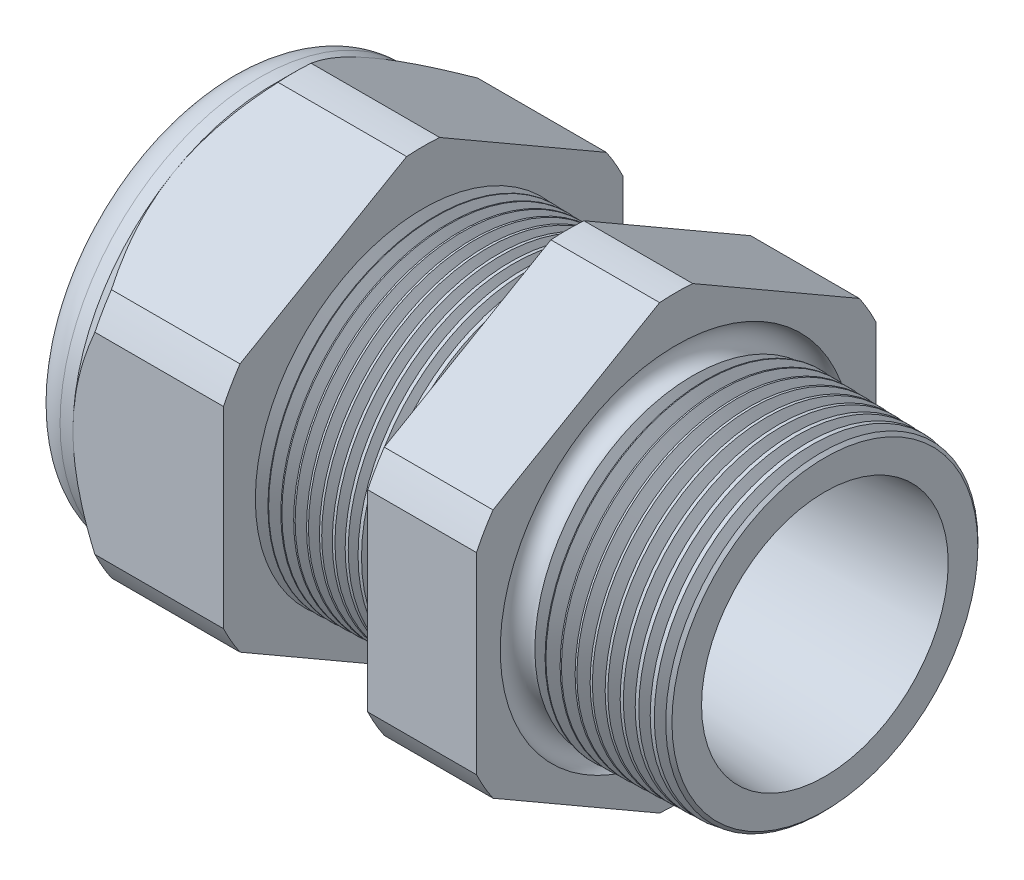
from build123d import *

# Parameters (mm, degrees)
SKETCH12_OUTSIDE_W = 65.04
SKETCH12_OUTSIDE_H = 65.04
CUT_EXTRUDE2_DEPTH = 34.014
FILLET4_R          = 2.032
SKETCH19_OUTSIDE_W = 39.986
SKETCH19_OUTSIDE_H = 42.612
SKETCH19_OUTSIDE_R = 11.938
CUT_EXTRUDE3_DEPTH = 1.999996
CUT_EXTRUDE3_DRAFT = -45
CHAMFER1_SIZE      = 0.260919487
CHAMFER1_SIZE2     = 0.254
SKETCH21_R         = 5.969
PLUG_DEPTH         = 6.35
SKETCH22_R         = 5.715
CUT_EXTRUDE4_DEPTH = 0.508
SKETCH27_R         = 1.524
PLUGHOLES_DEPTH    = 36.306
CIRPATTERN1_COUNT  = 3
LPATTERN1_COUNT    = 11
LPATTERN1_PITCH    = 0.762
LPATTERN2_COUNT    = 10
LPATTERN2_PITCH    = 0.889
SKETCH32_R         = 0.889


with BuildPart() as part:
    # Sketch10 → Revolve2 (revolve)
    with BuildSketch(Plane.XY, mode=Mode.PRIVATE) as revolve2_sk:
        Polygon((-34.798, 5.969), (-22.998, 5.969), (1.016, 7.372171279), (1.016, 9.404171279), (-7.874, 9.636964122), (-7.874, 23.876), (-14.374, 23.876), (-14.374, 9.807172612), (-22.998, 10.033), (-22.998, 23.876), (-31.998, 23.876), (-31.998, 11.938), (-34.798, 11.938), align=None)
    revolve(revolve2_sk.sketch.rotate(Axis((0, 0, 0), (-1, 0, 0)), 90), axis=Axis((0, 0, 0), (-1, 0, 0)))  # turned: the seam where the file's is

    # Sketch12 outside → Cut-Extrude2 (cut, through all)
    with BuildSketch(Plane.ZY.offset(31.998)):
        Rectangle(SKETCH12_OUTSIDE_W, SKETCH12_OUTSIDE_H)
        with BuildLine():
            Line((-0.98819228, 13.214281948), (-10.94980772, 7.462940592))
            ThreePointArc((-10.94980772, 7.462940592), (-11.47585851, 6.62559), (-11.938, 5.751341356))
            Line((-11.938, 5.751341356), (-11.938, -5.751341356))
            ThreePointArc((-11.938, -5.751341356), (-11.47585851, -6.62559), (-10.94980772, -7.462940592))
            Line((-10.94980772, -7.462940592), (-0.98819228, -13.214281948))
            ThreePointArc((-0.98819228, -13.214281948), (0, -13.25118), (0.98819228, -13.214281948))
            Line((0.98819228, -13.214281948), (10.94980772, -7.462940592))
            ThreePointArc((10.94980772, -7.462940592), (11.47585851, -6.62559), (11.938, -5.751341356))
            Line((11.938, -5.751341356), (11.938, 5.751341356))
            ThreePointArc((11.938, 5.751341356), (11.47585851, 6.62559), (10.94980772, 7.462940592))
            Line((10.94980772, 7.462940592), (0.98819228, 13.214281948))
            ThreePointArc((0.98819228, 13.214281948), (0, 13.25118), (-0.98819228, 13.214281948))
        make_face(mode=Mode.SUBTRACT)
    extrude(amount=-CUT_EXTRUDE2_DEPTH, mode=Mode.SUBTRACT)

    # Fillet4
    fillet4_edges = [part.edges().sort_by_distance(p)[0] for p in [
        (-34.798, 0, 11.938),
    ]]
    fillet(fillet4_edges, radius=FILLET4_R)


with BuildPart() as cut_extrude3_tool:
    # Sketch19 outside → Cut-Extrude3 (with draft: the straight prism first)
    with BuildSketch(Plane.ZY.offset(31.998)):
        Rectangle(SKETCH19_OUTSIDE_W, SKETCH19_OUTSIDE_H)
        Circle(SKETCH19_OUTSIDE_R, mode=Mode.SUBTRACT)
    extrude(amount=-CUT_EXTRUDE3_DEPTH)
    # Cut-Extrude3: the draft: its side faces are tilted about the plane it starts from
    cut_extrude3_sides = [cut_extrude3_tool.faces().sort_by_distance(p)[0] for p in [
        (-30.998002, -21.306, 0),
        (-30.998002, 0, 19.993),
        (-30.998002, 21.306, 0),
        (-30.998002, 0, -19.993),
        (-30.998002, 0, -11.938),
    ]]
    draft(cut_extrude3_sides, Plane.ZY.offset(31.998), CUT_EXTRUDE3_DRAFT)


with BuildPart() as part_1:
    add(part.part)

    # Cut-Extrude3: cut by cut_extrude3_tool
    add(cut_extrude3_tool.part, mode=Mode.SUBTRACT)

    # Chamfer1
    chamfer1_edges = [part_1.edges().sort_by_distance(p)[0] for p in [
        (1.016, 0, 9.404171279),
    ]]
    chamfer1_side = [part_1.faces().sort_by_distance(p)[0] for p in [
        (1.016, 0, 7.638161411),
    ]]
    chamfer(chamfer1_edges, length=CHAMFER1_SIZE, length2=CHAMFER1_SIZE2, reference=chamfer1_side[0])

    # Sketch29 → Cut-Revolve1 (revolve, cut)
    with BuildSketch(Plane.XY, mode=Mode.PRIVATE) as cut_revolve1_sk:
        Polygon((-22.998, 10.033), (-22.265016419, 10.013806149), (-22.648130572, 9.388620673), align=None)
    cut_revolve1 = revolve(cut_revolve1_sk.sketch.rotate(Axis((0, 0, 0), (-1, 0, 0)), 90), axis=Axis((0, 0, 0), (-1, 0, 0)), mode=Mode.SUBTRACT)  # turned: the seam where the file's is

    # LPattern1: Cut-Revolve1 ×11
    with Locations(*[(i * LPATTERN1_PITCH, 0, 0) for i in range(1, LPATTERN1_COUNT)]):
        add(cut_revolve1, mode=Mode.SUBTRACT)

    # Sketch30 → Cut-Revolve2 (revolve, cut)
    with BuildSketch(Plane.XY, mode=Mode.PRIVATE) as cut_revolve2_sk:
        Polygon((-7.874, 9.636964122), (-6.994419703, 9.613931502), (-7.454156686, 8.86370893), align=None)
    cut_revolve2 = revolve(cut_revolve2_sk.sketch.rotate(Axis((0, 0, 0), (-1, 0, 0)), 270), axis=Axis((0, 0, 0), (-1, 0, 0)), mode=Mode.SUBTRACT)  # turned: the seam where the file's is

    # LPattern2: Cut-Revolve2 ×10
    with Locations(*[(i * LPATTERN2_PITCH, 0, 0) for i in range(1, LPATTERN2_COUNT)]):
        add(cut_revolve2, mode=Mode.SUBTRACT)

    # Sketch32 → Cut-Revolve3 (revolve, cut)
    with BuildSketch(Plane.XY, mode=Mode.PRIVATE) as cut_revolve3_sk:
        with Locations((-7.747, 9.636964122)):
            Circle(SKETCH32_R)
    revolve(cut_revolve3_sk.sketch.rotate(Axis((0, 0, 0), (-1, 0, 0)), 270), axis=Axis((0, 0, 0), (-1, 0, 0)), mode=Mode.SUBTRACT)  # turned: the seam where the file's is


with BuildPart() as body_2:
    # Sketch21 → plug (new body)
    with BuildSketch(Plane.ZY.offset(34.798)):
        Circle(SKETCH21_R)
    extrude(amount=-PLUG_DEPTH)

    # Sketch22 → Cut-Extrude4 (cut)
    with BuildSketch(Plane.ZY.offset(34.798)):
        Circle(SKETCH22_R)
    extrude(amount=-CUT_EXTRUDE4_DEPTH, mode=Mode.SUBTRACT)

    # Sketch27 → plugholes (cut, through all)
    with BuildSketch(Plane.ZY.offset(34.29)):
        with Locations((-4.184904, 0)):
            Circle(SKETCH27_R)
    plugholes = extrude(amount=-PLUGHOLES_DEPTH, mode=Mode.SUBTRACT)

    # CirPattern1: plugholes ×3 about axis
    cirpattern1_axis = Axis((0, 0, 0), (1, 0, 0))
    for i in range(1, CIRPATTERN1_COUNT):
        add(plugholes.rotate(cirpattern1_axis, i * 360 / CIRPATTERN1_COUNT), mode=Mode.SUBTRACT)


solid = Compound([part_1.part, body_2.part])
